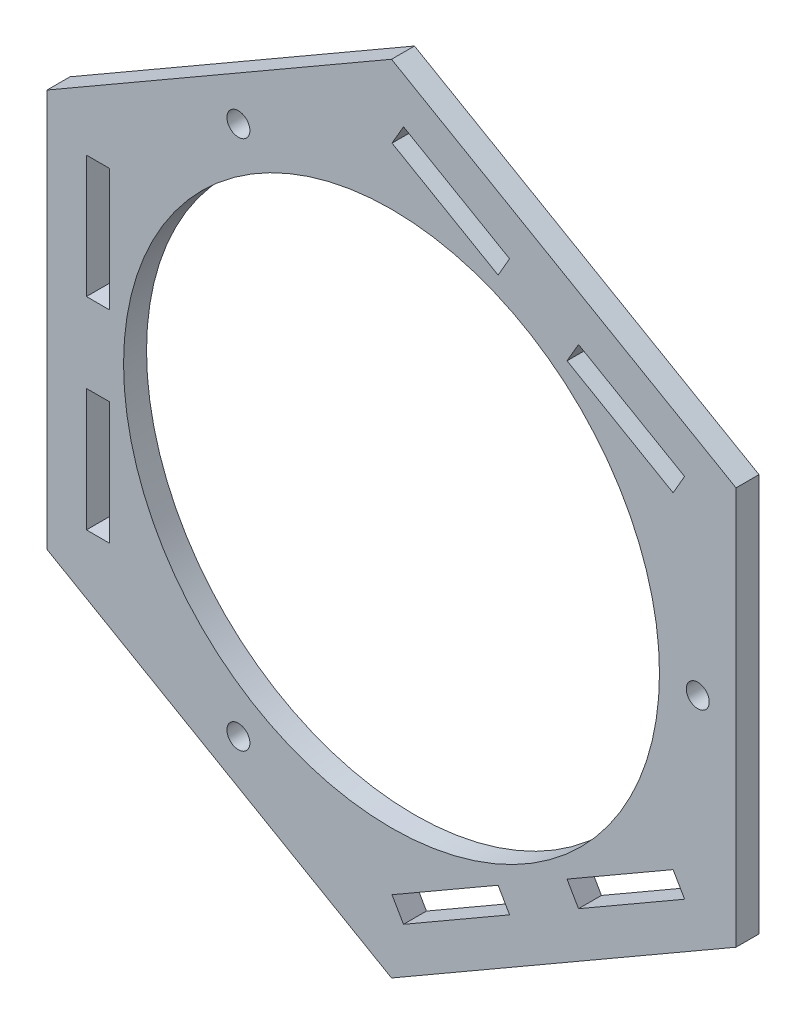
from build123d import *

# Parameters (mm, degrees)
SKETCH_2_R                         = 35
EXTRUDE_1_DEPTH                    = 3
SKETCH_1_W                         = 3
SKETCH_1_H                         = 8
CUT_EXTRUDE_1_DEPTH                = 3
PATTERN_CIRCULAR_1_COUNT           = 3
PATTERN_CIRCULAR_1_COPY_1_SKETCH_W = 3
PATTERN_CIRCULAR_1_COPY_1_SKETCH_H = 8
PATTERN_CIRCULAR_1_COPY_1_DEPTH    = 3
PATTERN_CIRCULAR_1_COPY_2_SKETCH_W = 3
PATTERN_CIRCULAR_1_COPY_2_SKETCH_H = 8
PATTERN_CIRCULAR_1_COPY_2_DEPTH    = 3
SKETCH_3_R                         = 1.5
CUT_EXTRUDE_3_DEPTH                = 10


with BuildPart() as part:
    # Эскиз2 → Бобышка-Вытянуть1 (new body)
    with BuildSketch(Plane.XY):
        Polygon((0, 51.961524227), (-45, 25.980762114), (-45, -25.980762114), (0, -51.961524227), (45, -25.980762114), (45, 25.980762114), align=None)
        Circle(SKETCH_2_R, mode=Mode.SUBTRACT)
    extrude(amount=EXTRUDE_1_DEPTH)

    # Эскиз1 → Вырез-Вытянуть1 (cut)
    with BuildSketch(Plane.XY):
        with Locations((-38.34595, -17.19729)):
            Rectangle(SKETCH_1_W, SKETCH_1_H)
        with Locations((-38.34595, -9.19729)):
            Rectangle(SKETCH_1_W, SKETCH_1_H)
    cut_extrude_1 = extrude(amount=CUT_EXTRUDE_1_DEPTH, mode=Mode.SUBTRACT)

    # Зеркальное отражение1: Вырез-Вытянуть1 across plane
    add(cut_extrude_1.mirror(Plane.ZX), mode=Mode.SUBTRACT)

    # Круговой массив1: Вырез-Вытянуть1 ×3 about axis
    pattern_circular_1_axis = Axis((0, 0, 0), (0, 0, 1))
    for i in range(1, PATTERN_CIRCULAR_1_COUNT):
        add(cut_extrude_1.rotate(pattern_circular_1_axis, i * 360 / PATTERN_CIRCULAR_1_COUNT), mode=Mode.SUBTRACT)

    # Круговой массив1 copy 1 sketch → Круговой массив1 copy 1 (cut)
    with BuildSketch(Plane(origin=(0, 0, 0), x_dir=(-0.5, 0.866025404, 0), z_dir=(0, 0, 1))):
        with Locations((-38.34595, 17.19729)):
            Rectangle(PATTERN_CIRCULAR_1_COPY_1_SKETCH_W, PATTERN_CIRCULAR_1_COPY_1_SKETCH_H)
        with Locations((-38.34595, 9.19729)):
            Rectangle(PATTERN_CIRCULAR_1_COPY_1_SKETCH_W, PATTERN_CIRCULAR_1_COPY_1_SKETCH_H)
    extrude(amount=PATTERN_CIRCULAR_1_COPY_1_DEPTH, mode=Mode.SUBTRACT)

    # Круговой массив1 copy 2 sketch → Круговой массив1 copy 2 (cut)
    with BuildSketch(Plane(origin=(0, 0, 0), x_dir=(-0.5, -0.866025404, 0), z_dir=(0, 0, 1))):
        with Locations((-38.34595, 17.19729)):
            Rectangle(PATTERN_CIRCULAR_1_COPY_2_SKETCH_W, PATTERN_CIRCULAR_1_COPY_2_SKETCH_H)
        with Locations((-38.34595, 9.19729)):
            Rectangle(PATTERN_CIRCULAR_1_COPY_2_SKETCH_W, PATTERN_CIRCULAR_1_COPY_2_SKETCH_H)
    extrude(amount=PATTERN_CIRCULAR_1_COPY_2_DEPTH, mode=Mode.SUBTRACT)

    # Эскиз3 → Вырез-Вытянуть3 (cut)
    with BuildSketch(Plane.XY):
        with Locations((40, 0)):
            Circle(SKETCH_3_R)
        with Locations((-20, -34.641016151)):
            Circle(SKETCH_3_R)
        with Locations((-20, 34.641016151)):
            Circle(SKETCH_3_R)
    extrude(amount=CUT_EXTRUDE_3_DEPTH, mode=Mode.SUBTRACT)


solid = part.part
